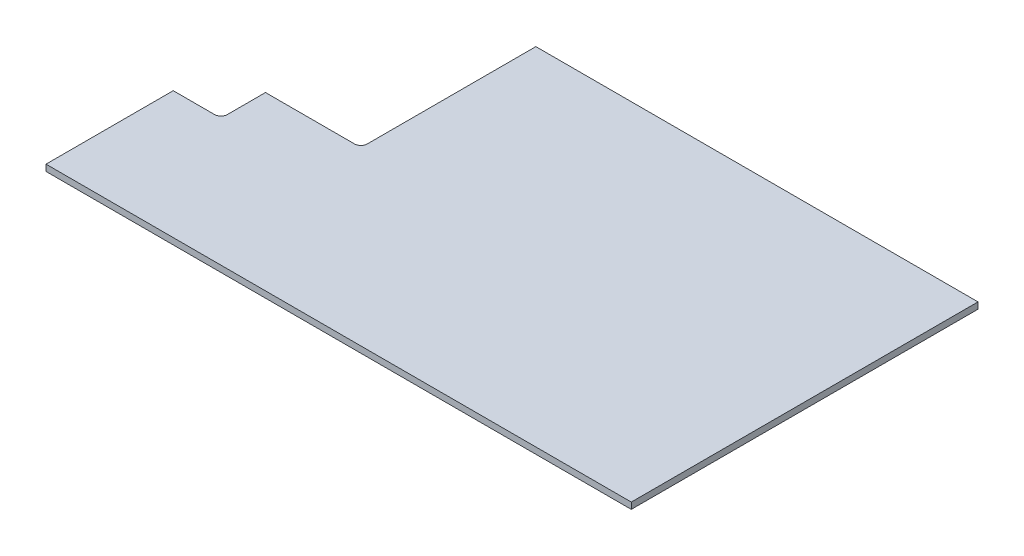
from build123d import *

# Parameters (mm, degrees)
BOSS_EXTRUDE1_DEPTH = 1
FILLET1_R           = 1


with BuildPart() as part:
    # Sketch1 → Boss-Extrude1 (new body)
    with BuildSketch(Plane(origin=(0, 0, 0), x_dir=(1, 0, 0), z_dir=(0, 1, 0))):
        Polygon((0, 0), (0, 27.5), (69.5, 27.5), (69.5, -27), (-22.5, -27), (-22.5, -7), (-15, -7), (-15, 0), align=None)
    extrude(amount=BOSS_EXTRUDE1_DEPTH)

    # Fillet1
    fillet1_edges = [part.edges().sort_by_distance(p)[0] for p in [
        (0, 0.5, 0),
        (-15, 0.5, 7),
    ]]
    fillet(fillet1_edges, radius=FILLET1_R)


solid = part.part
